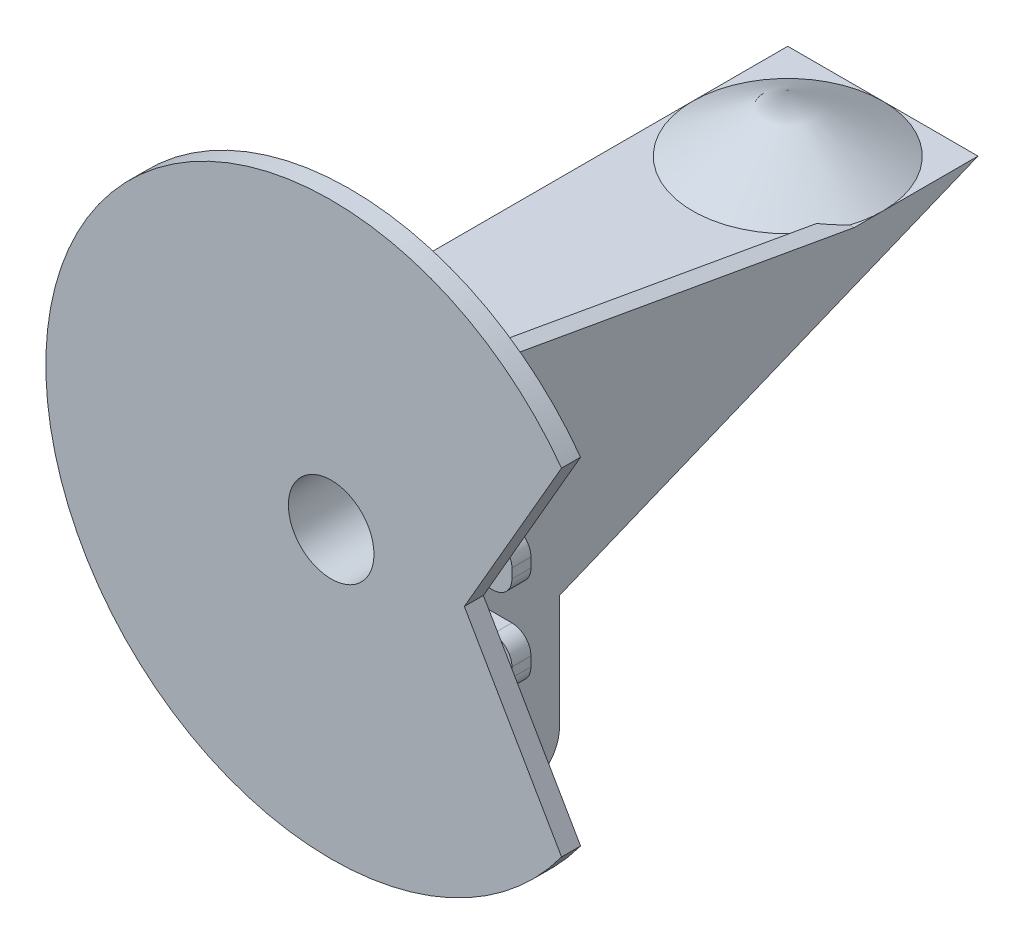
from build123d import *

# Parameters (mm, degrees)
SZKIC1_W                     = 100
SZKIC1_H                     = 100
DODANIE_WYCI_GNI_CIE1_DEPTH  = 40
SZKIC3_R                     = 22.5
WYTNIJ_WYCI_GNI_CIE1_DEPTH   = 41
SZKIC4_W                     = 100
SZKIC4_H                     = 10
DODANIE_WYCI_GNI_CIE2_DEPTH  = 30
DODANIE_WYCI_GNI_CIE3_DEPTH  = 10
DODANIE_WYCI_GNI_CIE4_DEPTH  = 10
DODANIE_WYCI_GNI_CIE5_DEPTH  = 10
SZKIC11_W                    = 15
SZKIC11_H                    = 50
DODANIE_WYCI_GNI_CIE6_DEPTH  = 70
SZKIC12_R                    = 15
DODANIE_WYCI_GNI_CIE7_DEPTH  = 125
SZKIC13_R                    = 15
DODANIE_WYCI_GNI_CIE8_DEPTH  = 30
DODANIE_WYCI_GNI_CIE9_DEPTH  = 10
ZAOKR_GLENIE1_R              = 20
SZKIC15_W                    = 50
SZKIC15_H                    = 185
DODANIE_WYCI_GNI_CIE10_DEPTH = 10
DODANIE_WYCI_GNI_CIE11_REACH = 52
SZKIC17_W                    = 50
SZKIC17_H                    = 30
SZKIC18_W                    = 100
SZKIC18_H                    = 100
DODANIE_WYCI_GNI_CIE12_DEPTH = 10
DODANIE_WYCI_GNI_CIE13_DEPTH = 10
WYTNIJ_WYCI_GNI_CIE2_REACH   = 202
SZKIC20_R                    = 5
SZKIC21_W                    = 10
SZKIC21_H                    = 25
DODANIE_WYCI_GNI_CIE14_DEPTH = 25
ZAOKR_GLENIE2_R              = 10
WYTNIJ_WYCI_GNI_CIE3_REACH   = 32
SZKIC22_R                    = 5


with BuildPart() as part:
    # Szkic1 → Dodanie-wyciągnięcie1 (new body)
    with BuildSketch(Plane.XY):
        Rectangle(SZKIC1_W, SZKIC1_H)
    extrude(amount=DODANIE_WYCI_GNI_CIE1_DEPTH)

    # Szkic3 → Wytnij-wyciągnięcie1 (cut, through all)
    with BuildSketch(Plane.XY.offset(40)):
        Circle(SZKIC3_R)
    extrude(amount=-WYTNIJ_WYCI_GNI_CIE1_DEPTH, mode=Mode.SUBTRACT)

    # Szkic4 → Dodanie-wyciągnięcie2 (add)
    with BuildSketch(Plane(origin=(0, 0, 0), x_dir=(-1, 0, 0), z_dir=(0, 0, -1))):
        with Locations((0, -45)):
            Rectangle(SZKIC4_W, SZKIC4_H)
    extrude(amount=DODANIE_WYCI_GNI_CIE2_DEPTH)

    # Szkic5 → Dodanie-wyciągnięcie3 (add)
    with BuildSketch(Plane.ZY.offset(50)):
        Polygon((-30, -40), (-250, 50), (0, 50), (0, -40), align=None)
    extrude(amount=-DODANIE_WYCI_GNI_CIE3_DEPTH)

    # Szkic6 → Dodanie-wyciągnięcie4 (add)
    with BuildSketch(Plane(origin=(50, 0, 0), x_dir=(0, 0, -1), z_dir=(1, 0, 0))):
        Polygon((30, -40), (250, 50), (0, 50), (0, -40), align=None)
    extrude(amount=-DODANIE_WYCI_GNI_CIE4_DEPTH)

    # Szkic7 → Dodanie-wyciągnięcie5 (add)
    with BuildSketch(Plane(origin=(0, 50, 0), x_dir=(1, 0, 0), z_dir=(0, 1, 0))):
        Polygon((40, 250), (-40, 250), (-40, 30), (-40, 0), (40, 0), align=None)
    extrude(amount=-DODANIE_WYCI_GNI_CIE5_DEPTH)

    # Szkic10 → Obrót1 (revolve)
    with BuildSketch(Plane(origin=(0, 0, -200), x_dir=(-1, 0, 0), z_dir=(0, 0, -1))):
        Polygon((0, 50), (0, 80), (-50, 50), align=None)
    revolve(axis=Axis((0, 50, -200), (0, 1, 0)))

    # Szkic11 → Dodanie-wyciągnięcie6 (add)
    with BuildSketch(Plane.XZ.offset(50)):
        with Locations((42.5, -5)):
            Rectangle(SZKIC11_W, SZKIC11_H)
    extrude(amount=DODANIE_WYCI_GNI_CIE6_DEPTH)

    # Szkic12 → Dodanie-wyciągnięcie7 (add)
    with BuildSketch(Plane.ZY.offset(-35)):
        with Locations((-5, -85)):
            Circle(SZKIC12_R)
    extrude(amount=DODANIE_WYCI_GNI_CIE7_DEPTH)

    # Szkic13 → Dodanie-wyciągnięcie8 (add)
    with BuildSketch(Plane.ZY.offset(50)):
        with Locations((-40, 0)):
            Circle(SZKIC13_R)
    extrude(amount=DODANIE_WYCI_GNI_CIE8_DEPTH)

    # Szkic14 → Dodanie-wyciągnięcie9 (add)
    with BuildSketch(Plane.ZY.offset(60)):
        Polygon((-69.010894517, 20.037063975), (-26.999775325, 36.163621704), (26.755417107, -103.87344227), (-15.255702085, -120), align=None)
    extrude(amount=DODANIE_WYCI_GNI_CIE9_DEPTH)

    # Zaokrąglenie1
    zaokr_glenie1_edges = [part.edges().sort_by_distance(p)[0] for p in [
        (-65, 20.037063975, -69.010894517),
        (-65, -120, -15.255702085),
        (-65, -103.87344227, 26.755417107),
        (-65, 36.163621704, -26.999775325),
        (42.5, -120, 20),
        (42.5, -120, -30),
    ]]
    fillet(zaokr_glenie1_edges, radius=ZAOKR_GLENIE1_R)

    # Szkic15 → Dodanie-wyciągnięcie10 (add)
    with BuildSketch(Plane.ZY.offset(90)):
        with Locations((-5, -27.5)):
            Rectangle(SZKIC15_W, SZKIC15_H)
    extrude(amount=DODANIE_WYCI_GNI_CIE10_DEPTH)

    # Szkic17 → Dodanie-wyciągnięcie11 (add, up to next)
    with BuildSketch(Plane.ZY.offset(50), mode=Mode.PRIVATE) as dodanie_wyci_gni_cie11_sk1:
        with Locations((-5, 50)):
            Rectangle(SZKIC17_W, SZKIC17_H)
    dodanie_wyci_gni_cie11_tool1 = extrude(dodanie_wyci_gni_cie11_sk1.sketch, amount=DODANIE_WYCI_GNI_CIE11_REACH, mode=Mode.PRIVATE) - part.part
    add(dodanie_wyci_gni_cie11_tool1.solids().sort_by_distance((-50, 50, -5))[0])

    # Szkic18 → Dodanie-wyciągnięcie12 (add)
    with BuildSketch(Plane.XY.offset(40)):
        with BuildLine():
            Line((70, 0), (121.10211367, 88.511457251))
            ThreePointArc((121.10211367, 88.511457251), (-150, 0), (121.10211367, -88.511457251))
            Line((121.10211367, -88.511457251), (70, 0))
        make_face()
        Rectangle(SZKIC18_W, SZKIC18_H, mode=Mode.SUBTRACT)
    extrude(amount=-DODANIE_WYCI_GNI_CIE12_DEPTH)

    # Szkic19 → Dodanie-wyciągnięcie13 (add)
    with BuildSketch(Plane(origin=(50, 0, 0), x_dir=(0, 0, -1), z_dir=(1, 0, 0))):
        Polygon((-30, 50), (-9.958560776, 84.617058134), (185, 50), align=None)
    extrude(amount=-DODANIE_WYCI_GNI_CIE13_DEPTH)

    # Szkic20 → Wytnij-wyciągnięcie2 (cut, up to next)
    with BuildSketch(Plane(origin=(50, 0, 0), x_dir=(0, 0, -1), z_dir=(1, 0, 0)), mode=Mode.PRIVATE) as wytnij_wyci_gni_cie2_sk1:
        with Locations((-4.958560776, 69.617058134)):
            Circle(SZKIC20_R)
    wytnij_wyci_gni_cie2_tool1 = extrude(wytnij_wyci_gni_cie2_sk1.sketch, amount=-WYTNIJ_WYCI_GNI_CIE2_REACH, mode=Mode.PRIVATE) & part.part
    add(wytnij_wyci_gni_cie2_tool1.solids().sort_by_distance((50, 69.617058, 4.958561))[0], mode=Mode.SUBTRACT)

    # Szkic21 → Dodanie-wyciągnięcie14 (add)
    with BuildSketch(Plane(origin=(50, 0, 0), x_dir=(0, 0, -1), z_dir=(1, 0, 0))):
        with Locations((-15, 7.5)):
            Rectangle(SZKIC21_W, SZKIC21_H)
        with Locations((-15, -37.5)):
            Rectangle(SZKIC21_W, SZKIC21_H)
    extrude(amount=DODANIE_WYCI_GNI_CIE14_DEPTH)

    # Zaokrąglenie2
    zaokr_glenie2_edges = [part.edges().sort_by_distance(p)[0] for p in [
        (45, 84.617058134, 9.958560776),
        (75, 20, 15),
        (75, -5, 15),
        (75, -25, 15),
        (75, -50, 15),
    ]]
    fillet(zaokr_glenie2_edges, radius=ZAOKR_GLENIE2_R)

    # Szkic22 → Wytnij-wyciągnięcie3 (cut, up to next)
    with BuildSketch(Plane(origin=(0, 0, 10), x_dir=(-1, 0, 0), z_dir=(0, 0, -1)), mode=Mode.PRIVATE) as wytnij_wyci_gni_cie3_sk1:
        with Locations((-63, 7.5)):
            Circle(SZKIC22_R)
    wytnij_wyci_gni_cie3_tool1 = extrude(wytnij_wyci_gni_cie3_sk1.sketch, amount=-WYTNIJ_WYCI_GNI_CIE3_REACH, mode=Mode.PRIVATE) & part.part
    add(wytnij_wyci_gni_cie3_tool1.solids().sort_by_distance((63, 7.5, 10))[0], mode=Mode.SUBTRACT)
    # Szkic22 → Wytnij-wyciągnięcie3 (cut, up to next)
    with BuildSketch(Plane(origin=(0, 0, 10), x_dir=(-1, 0, 0), z_dir=(0, 0, -1)), mode=Mode.PRIVATE) as wytnij_wyci_gni_cie3_sk2:
        with Locations((-63, -37.5)):
            Circle(SZKIC22_R)
    wytnij_wyci_gni_cie3_tool2 = extrude(wytnij_wyci_gni_cie3_sk2.sketch, amount=-WYTNIJ_WYCI_GNI_CIE3_REACH, mode=Mode.PRIVATE) & part.part
    add(wytnij_wyci_gni_cie3_tool2.solids().sort_by_distance((63, -37.5, 10))[0], mode=Mode.SUBTRACT)


solid = part.part
